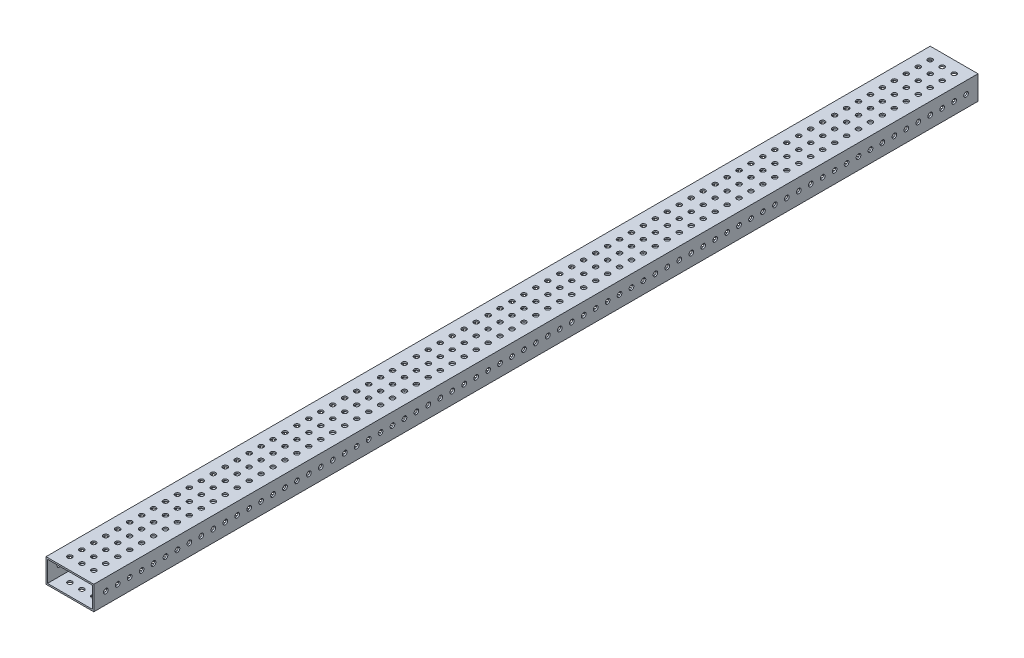
from build123d import *

# Parameters (mm, degrees)
SKETCH1_W           = 50.8
SKETCH1_H           = 25.4
SKETCH1_W_2         = 47.625
SKETCH1_H_2         = 22.225
BOSS_EXTRUDE1_DEPTH = 939.8
SKETCH2_R           = 2.4892
CUT_EXTRUDE1_DEPTH  = 51.8
SKETCH3_R           = 2.4892
CUT_EXTRUDE2_DEPTH  = 26.4


with BuildPart() as part:
    # Sketch1 → Boss-Extrude1 (new body)
    with BuildSketch(Plane.XY):
        with Locations((25.4, 12.7)):
            Rectangle(SKETCH1_W, SKETCH1_H)
        with Locations((25.4, 12.7)):
            Rectangle(SKETCH1_W_2, SKETCH1_H_2, mode=Mode.SUBTRACT)
    extrude(amount=BOSS_EXTRUDE1_DEPTH)

    # Sketch2 → Cut-Extrude1 (cut, through all)
    with BuildSketch(Plane(origin=(50.8, 0, 0), x_dir=(0, 0, -1), z_dir=(1, 0, 0))):
        with Locations((-927.1, 12.7)):
            Circle(SKETCH2_R)
        with Locations((-914.4, 12.7)):
            Circle(SKETCH2_R)
        with Locations((-901.7, 12.7)):
            Circle(SKETCH2_R)
        with Locations((-889, 12.7)):
            Circle(SKETCH2_R)
        with Locations((-876.3, 12.7)):
            Circle(SKETCH2_R)
        with Locations((-863.6, 12.7)):
            Circle(SKETCH2_R)
        with Locations((-850.9, 12.7)):
            Circle(SKETCH2_R)
        with Locations((-838.2, 12.7)):
            Circle(SKETCH2_R)
        with Locations((-825.5, 12.7)):
            Circle(SKETCH2_R)
        with Locations((-812.8, 12.7)):
            Circle(SKETCH2_R)
        with Locations((-800.1, 12.7)):
            Circle(SKETCH2_R)
        with Locations((-787.4, 12.7)):
            Circle(SKETCH2_R)
        with Locations((-774.7, 12.7)):
            Circle(SKETCH2_R)
        with Locations((-762, 12.7)):
            Circle(SKETCH2_R)
        with Locations((-749.3, 12.7)):
            Circle(SKETCH2_R)
        with Locations((-736.6, 12.7)):
            Circle(SKETCH2_R)
        with Locations((-723.9, 12.7)):
            Circle(SKETCH2_R)
        with Locations((-711.2, 12.7)):
            Circle(SKETCH2_R)
        with Locations((-698.5, 12.7)):
            Circle(SKETCH2_R)
        with Locations((-685.8, 12.7)):
            Circle(SKETCH2_R)
        with Locations((-673.1, 12.7)):
            Circle(SKETCH2_R)
        with Locations((-660.4, 12.7)):
            Circle(SKETCH2_R)
        with Locations((-647.7, 12.7)):
            Circle(SKETCH2_R)
        with Locations((-635, 12.7)):
            Circle(SKETCH2_R)
        with Locations((-622.3, 12.7)):
            Circle(SKETCH2_R)
        with Locations((-609.6, 12.7)):
            Circle(SKETCH2_R)
        with Locations((-596.9, 12.7)):
            Circle(SKETCH2_R)
        with Locations((-584.2, 12.7)):
            Circle(SKETCH2_R)
        with Locations((-571.5, 12.7)):
            Circle(SKETCH2_R)
        with Locations((-558.8, 12.7)):
            Circle(SKETCH2_R)
        with Locations((-546.1, 12.7)):
            Circle(SKETCH2_R)
        with Locations((-533.4, 12.7)):
            Circle(SKETCH2_R)
        with Locations((-520.7, 12.7)):
            Circle(SKETCH2_R)
        with Locations((-508, 12.7)):
            Circle(SKETCH2_R)
        with Locations((-495.3, 12.7)):
            Circle(SKETCH2_R)
        with Locations((-482.6, 12.7)):
            Circle(SKETCH2_R)
        with Locations((-469.9, 12.7)):
            Circle(SKETCH2_R)
        with Locations((-457.2, 12.7)):
            Circle(SKETCH2_R)
        with Locations((-444.5, 12.7)):
            Circle(SKETCH2_R)
        with Locations((-431.8, 12.7)):
            Circle(SKETCH2_R)
        with Locations((-419.1, 12.7)):
            Circle(SKETCH2_R)
        with Locations((-406.4, 12.7)):
            Circle(SKETCH2_R)
        with Locations((-393.7, 12.7)):
            Circle(SKETCH2_R)
        with Locations((-381, 12.7)):
            Circle(SKETCH2_R)
        with Locations((-368.3, 12.7)):
            Circle(SKETCH2_R)
        with Locations((-355.6, 12.7)):
            Circle(SKETCH2_R)
        with Locations((-342.9, 12.7)):
            Circle(SKETCH2_R)
        with Locations((-330.2, 12.7)):
            Circle(SKETCH2_R)
        with Locations((-317.5, 12.7)):
            Circle(SKETCH2_R)
        with Locations((-304.8, 12.7)):
            Circle(SKETCH2_R)
        with Locations((-292.1, 12.7)):
            Circle(SKETCH2_R)
        with Locations((-279.4, 12.7)):
            Circle(SKETCH2_R)
        with Locations((-266.7, 12.7)):
            Circle(SKETCH2_R)
        with Locations((-254, 12.7)):
            Circle(SKETCH2_R)
        with Locations((-241.3, 12.7)):
            Circle(SKETCH2_R)
        with Locations((-228.6, 12.7)):
            Circle(SKETCH2_R)
        with Locations((-215.9, 12.7)):
            Circle(SKETCH2_R)
        with Locations((-203.2, 12.7)):
            Circle(SKETCH2_R)
        with Locations((-190.5, 12.7)):
            Circle(SKETCH2_R)
        with Locations((-177.8, 12.7)):
            Circle(SKETCH2_R)
        with Locations((-165.1, 12.7)):
            Circle(SKETCH2_R)
        with Locations((-152.4, 12.7)):
            Circle(SKETCH2_R)
        with Locations((-139.7, 12.7)):
            Circle(SKETCH2_R)
        with Locations((-127, 12.7)):
            Circle(SKETCH2_R)
        with Locations((-114.3, 12.7)):
            Circle(SKETCH2_R)
        with Locations((-101.6, 12.7)):
            Circle(SKETCH2_R)
        with Locations((-88.9, 12.7)):
            Circle(SKETCH2_R)
        with Locations((-76.2, 12.7)):
            Circle(SKETCH2_R)
        with Locations((-63.5, 12.7)):
            Circle(SKETCH2_R)
        with Locations((-50.8, 12.7)):
            Circle(SKETCH2_R)
        with Locations((-38.1, 12.7)):
            Circle(SKETCH2_R)
        with Locations((-25.4, 12.7)):
            Circle(SKETCH2_R)
        with Locations((-12.7, 12.7)):
            Circle(SKETCH2_R)
    extrude(amount=-CUT_EXTRUDE1_DEPTH, mode=Mode.SUBTRACT)

    # Sketch3 → Cut-Extrude2 (cut, through all)
    with BuildSketch(Plane(origin=(0, 25.4, 0), x_dir=(1, 0, 0), z_dir=(0, 1, 0))):
        with Locations((12.7, -12.7)):
            Circle(SKETCH3_R)
        with Locations((25.4, -12.7)):
            Circle(SKETCH3_R)
        with Locations((38.1, -12.7)):
            Circle(SKETCH3_R)
        with Locations((25.4, -25.4)):
            Circle(SKETCH3_R)
        with Locations((38.1, -25.4)):
            Circle(SKETCH3_R)
        with Locations((25.4, -38.1)):
            Circle(SKETCH3_R)
        with Locations((38.1, -38.1)):
            Circle(SKETCH3_R)
        with Locations((25.4, -50.8)):
            Circle(SKETCH3_R)
        with Locations((38.1, -50.8)):
            Circle(SKETCH3_R)
        with Locations((25.4, -63.5)):
            Circle(SKETCH3_R)
        with Locations((38.1, -63.5)):
            Circle(SKETCH3_R)
        with Locations((25.4, -76.2)):
            Circle(SKETCH3_R)
        with Locations((38.1, -76.2)):
            Circle(SKETCH3_R)
        with Locations((25.4, -88.9)):
            Circle(SKETCH3_R)
        with Locations((38.1, -88.9)):
            Circle(SKETCH3_R)
        with Locations((25.4, -101.6)):
            Circle(SKETCH3_R)
        with Locations((38.1, -101.6)):
            Circle(SKETCH3_R)
        with Locations((25.4, -114.3)):
            Circle(SKETCH3_R)
        with Locations((38.1, -114.3)):
            Circle(SKETCH3_R)
        with Locations((25.4, -127)):
            Circle(SKETCH3_R)
        with Locations((38.1, -127)):
            Circle(SKETCH3_R)
        with Locations((25.4, -139.7)):
            Circle(SKETCH3_R)
        with Locations((38.1, -139.7)):
            Circle(SKETCH3_R)
        with Locations((25.4, -152.4)):
            Circle(SKETCH3_R)
        with Locations((38.1, -152.4)):
            Circle(SKETCH3_R)
        with Locations((25.4, -165.1)):
            Circle(SKETCH3_R)
        with Locations((38.1, -165.1)):
            Circle(SKETCH3_R)
        with Locations((25.4, -177.8)):
            Circle(SKETCH3_R)
        with Locations((38.1, -177.8)):
            Circle(SKETCH3_R)
        with Locations((25.4, -190.5)):
            Circle(SKETCH3_R)
        with Locations((38.1, -190.5)):
            Circle(SKETCH3_R)
        with Locations((25.4, -203.2)):
            Circle(SKETCH3_R)
        with Locations((38.1, -203.2)):
            Circle(SKETCH3_R)
        with Locations((25.4, -215.9)):
            Circle(SKETCH3_R)
        with Locations((38.1, -215.9)):
            Circle(SKETCH3_R)
        with Locations((25.4, -228.6)):
            Circle(SKETCH3_R)
        with Locations((38.1, -228.6)):
            Circle(SKETCH3_R)
        with Locations((25.4, -241.3)):
            Circle(SKETCH3_R)
        with Locations((38.1, -241.3)):
            Circle(SKETCH3_R)
        with Locations((25.4, -254)):
            Circle(SKETCH3_R)
        with Locations((38.1, -254)):
            Circle(SKETCH3_R)
        with Locations((25.4, -266.7)):
            Circle(SKETCH3_R)
        with Locations((38.1, -266.7)):
            Circle(SKETCH3_R)
        with Locations((25.4, -279.4)):
            Circle(SKETCH3_R)
        with Locations((38.1, -279.4)):
            Circle(SKETCH3_R)
        with Locations((25.4, -292.1)):
            Circle(SKETCH3_R)
        with Locations((38.1, -292.1)):
            Circle(SKETCH3_R)
        with Locations((25.4, -304.8)):
            Circle(SKETCH3_R)
        with Locations((38.1, -304.8)):
            Circle(SKETCH3_R)
        with Locations((25.4, -317.5)):
            Circle(SKETCH3_R)
        with Locations((38.1, -317.5)):
            Circle(SKETCH3_R)
        with Locations((25.4, -330.2)):
            Circle(SKETCH3_R)
        with Locations((38.1, -330.2)):
            Circle(SKETCH3_R)
        with Locations((25.4, -342.9)):
            Circle(SKETCH3_R)
        with Locations((38.1, -342.9)):
            Circle(SKETCH3_R)
        with Locations((25.4, -355.6)):
            Circle(SKETCH3_R)
        with Locations((38.1, -355.6)):
            Circle(SKETCH3_R)
        with Locations((25.4, -368.3)):
            Circle(SKETCH3_R)
        with Locations((38.1, -368.3)):
            Circle(SKETCH3_R)
        with Locations((25.4, -381)):
            Circle(SKETCH3_R)
        with Locations((38.1, -381)):
            Circle(SKETCH3_R)
        with Locations((25.4, -393.7)):
            Circle(SKETCH3_R)
        with Locations((38.1, -393.7)):
            Circle(SKETCH3_R)
        with Locations((25.4, -406.4)):
            Circle(SKETCH3_R)
        with Locations((38.1, -406.4)):
            Circle(SKETCH3_R)
        with Locations((25.4, -419.1)):
            Circle(SKETCH3_R)
        with Locations((38.1, -419.1)):
            Circle(SKETCH3_R)
        with Locations((25.4, -431.8)):
            Circle(SKETCH3_R)
        with Locations((38.1, -431.8)):
            Circle(SKETCH3_R)
        with Locations((25.4, -444.5)):
            Circle(SKETCH3_R)
        with Locations((38.1, -444.5)):
            Circle(SKETCH3_R)
        with Locations((25.4, -457.2)):
            Circle(SKETCH3_R)
        with Locations((38.1, -457.2)):
            Circle(SKETCH3_R)
        with Locations((25.4, -469.9)):
            Circle(SKETCH3_R)
        with Locations((38.1, -469.9)):
            Circle(SKETCH3_R)
        with Locations((25.4, -482.6)):
            Circle(SKETCH3_R)
        with Locations((38.1, -482.6)):
            Circle(SKETCH3_R)
        with Locations((25.4, -495.3)):
            Circle(SKETCH3_R)
        with Locations((38.1, -495.3)):
            Circle(SKETCH3_R)
        with Locations((25.4, -508)):
            Circle(SKETCH3_R)
        with Locations((38.1, -508)):
            Circle(SKETCH3_R)
        with Locations((25.4, -520.7)):
            Circle(SKETCH3_R)
        with Locations((38.1, -520.7)):
            Circle(SKETCH3_R)
        with Locations((25.4, -533.4)):
            Circle(SKETCH3_R)
        with Locations((38.1, -533.4)):
            Circle(SKETCH3_R)
        with Locations((25.4, -546.1)):
            Circle(SKETCH3_R)
        with Locations((38.1, -546.1)):
            Circle(SKETCH3_R)
        with Locations((25.4, -558.8)):
            Circle(SKETCH3_R)
        with Locations((38.1, -558.8)):
            Circle(SKETCH3_R)
        with Locations((25.4, -571.5)):
            Circle(SKETCH3_R)
        with Locations((38.1, -571.5)):
            Circle(SKETCH3_R)
        with Locations((25.4, -584.2)):
            Circle(SKETCH3_R)
        with Locations((38.1, -584.2)):
            Circle(SKETCH3_R)
        with Locations((25.4, -596.9)):
            Circle(SKETCH3_R)
        with Locations((38.1, -596.9)):
            Circle(SKETCH3_R)
        with Locations((25.4, -609.6)):
            Circle(SKETCH3_R)
        with Locations((38.1, -609.6)):
            Circle(SKETCH3_R)
        with Locations((25.4, -622.3)):
            Circle(SKETCH3_R)
        with Locations((38.1, -622.3)):
            Circle(SKETCH3_R)
        with Locations((25.4, -635)):
            Circle(SKETCH3_R)
        with Locations((38.1, -635)):
            Circle(SKETCH3_R)
        with Locations((25.4, -647.7)):
            Circle(SKETCH3_R)
        with Locations((38.1, -647.7)):
            Circle(SKETCH3_R)
        with Locations((25.4, -660.4)):
            Circle(SKETCH3_R)
        with Locations((38.1, -660.4)):
            Circle(SKETCH3_R)
        with Locations((25.4, -673.1)):
            Circle(SKETCH3_R)
        with Locations((38.1, -673.1)):
            Circle(SKETCH3_R)
        with Locations((25.4, -685.8)):
            Circle(SKETCH3_R)
        with Locations((38.1, -685.8)):
            Circle(SKETCH3_R)
        with Locations((25.4, -698.5)):
            Circle(SKETCH3_R)
        with Locations((38.1, -698.5)):
            Circle(SKETCH3_R)
        with Locations((25.4, -711.2)):
            Circle(SKETCH3_R)
        with Locations((38.1, -711.2)):
            Circle(SKETCH3_R)
        with Locations((25.4, -723.9)):
            Circle(SKETCH3_R)
        with Locations((38.1, -723.9)):
            Circle(SKETCH3_R)
        with Locations((25.4, -736.6)):
            Circle(SKETCH3_R)
        with Locations((38.1, -736.6)):
            Circle(SKETCH3_R)
        with Locations((25.4, -749.3)):
            Circle(SKETCH3_R)
        with Locations((38.1, -749.3)):
            Circle(SKETCH3_R)
        with Locations((25.4, -762)):
            Circle(SKETCH3_R)
        with Locations((38.1, -762)):
            Circle(SKETCH3_R)
        with Locations((25.4, -774.7)):
            Circle(SKETCH3_R)
        with Locations((38.1, -774.7)):
            Circle(SKETCH3_R)
        with Locations((25.4, -787.4)):
            Circle(SKETCH3_R)
        with Locations((38.1, -787.4)):
            Circle(SKETCH3_R)
        with Locations((25.4, -800.1)):
            Circle(SKETCH3_R)
        with Locations((38.1, -800.1)):
            Circle(SKETCH3_R)
        with Locations((25.4, -812.8)):
            Circle(SKETCH3_R)
        with Locations((38.1, -812.8)):
            Circle(SKETCH3_R)
        with Locations((25.4, -825.5)):
            Circle(SKETCH3_R)
        with Locations((38.1, -825.5)):
            Circle(SKETCH3_R)
        with Locations((25.4, -838.2)):
            Circle(SKETCH3_R)
        with Locations((38.1, -838.2)):
            Circle(SKETCH3_R)
        with Locations((25.4, -850.9)):
            Circle(SKETCH3_R)
        with Locations((38.1, -850.9)):
            Circle(SKETCH3_R)
        with Locations((25.4, -863.6)):
            Circle(SKETCH3_R)
        with Locations((38.1, -863.6)):
            Circle(SKETCH3_R)
        with Locations((25.4, -876.3)):
            Circle(SKETCH3_R)
        with Locations((38.1, -876.3)):
            Circle(SKETCH3_R)
        with Locations((25.4, -889)):
            Circle(SKETCH3_R)
        with Locations((38.1, -889)):
            Circle(SKETCH3_R)
        with Locations((25.4, -901.7)):
            Circle(SKETCH3_R)
        with Locations((38.1, -901.7)):
            Circle(SKETCH3_R)
        with Locations((25.4, -914.4)):
            Circle(SKETCH3_R)
        with Locations((38.1, -914.4)):
            Circle(SKETCH3_R)
        with Locations((25.4, -927.1)):
            Circle(SKETCH3_R)
        with Locations((38.1, -927.1)):
            Circle(SKETCH3_R)
        with Locations((12.7, -25.4)):
            Circle(SKETCH3_R)
        with Locations((12.7, -38.1)):
            Circle(SKETCH3_R)
        with Locations((12.7, -50.8)):
            Circle(SKETCH3_R)
        with Locations((12.7, -63.5)):
            Circle(SKETCH3_R)
        with Locations((12.7, -76.2)):
            Circle(SKETCH3_R)
        with Locations((12.7, -88.9)):
            Circle(SKETCH3_R)
        with Locations((12.7, -101.6)):
            Circle(SKETCH3_R)
        with Locations((12.7, -114.3)):
            Circle(SKETCH3_R)
        with Locations((12.7, -127)):
            Circle(SKETCH3_R)
        with Locations((12.7, -139.7)):
            Circle(SKETCH3_R)
        with Locations((12.7, -152.4)):
            Circle(SKETCH3_R)
        with Locations((12.7, -165.1)):
            Circle(SKETCH3_R)
        with Locations((12.7, -177.8)):
            Circle(SKETCH3_R)
        with Locations((12.7, -190.5)):
            Circle(SKETCH3_R)
        with Locations((12.7, -203.2)):
            Circle(SKETCH3_R)
        with Locations((12.7, -215.9)):
            Circle(SKETCH3_R)
        with Locations((12.7, -228.6)):
            Circle(SKETCH3_R)
        with Locations((12.7, -241.3)):
            Circle(SKETCH3_R)
        with Locations((12.7, -254)):
            Circle(SKETCH3_R)
        with Locations((12.7, -266.7)):
            Circle(SKETCH3_R)
        with Locations((12.7, -279.4)):
            Circle(SKETCH3_R)
        with Locations((12.7, -292.1)):
            Circle(SKETCH3_R)
        with Locations((12.7, -304.8)):
            Circle(SKETCH3_R)
        with Locations((12.7, -317.5)):
            Circle(SKETCH3_R)
        with Locations((12.7, -330.2)):
            Circle(SKETCH3_R)
        with Locations((12.7, -342.9)):
            Circle(SKETCH3_R)
        with Locations((12.7, -355.6)):
            Circle(SKETCH3_R)
        with Locations((12.7, -368.3)):
            Circle(SKETCH3_R)
        with Locations((12.7, -381)):
            Circle(SKETCH3_R)
        with Locations((12.7, -393.7)):
            Circle(SKETCH3_R)
        with Locations((12.7, -406.4)):
            Circle(SKETCH3_R)
        with Locations((12.7, -419.1)):
            Circle(SKETCH3_R)
        with Locations((12.7, -431.8)):
            Circle(SKETCH3_R)
        with Locations((12.7, -444.5)):
            Circle(SKETCH3_R)
        with Locations((12.7, -457.2)):
            Circle(SKETCH3_R)
        with Locations((12.7, -469.9)):
            Circle(SKETCH3_R)
        with Locations((12.7, -482.6)):
            Circle(SKETCH3_R)
        with Locations((12.7, -495.3)):
            Circle(SKETCH3_R)
        with Locations((12.7, -508)):
            Circle(SKETCH3_R)
        with Locations((12.7, -520.7)):
            Circle(SKETCH3_R)
        with Locations((12.7, -533.4)):
            Circle(SKETCH3_R)
        with Locations((12.7, -546.1)):
            Circle(SKETCH3_R)
        with Locations((12.7, -558.8)):
            Circle(SKETCH3_R)
        with Locations((12.7, -571.5)):
            Circle(SKETCH3_R)
        with Locations((12.7, -584.2)):
            Circle(SKETCH3_R)
        with Locations((12.7, -596.9)):
            Circle(SKETCH3_R)
        with Locations((12.7, -609.6)):
            Circle(SKETCH3_R)
        with Locations((12.7, -622.3)):
            Circle(SKETCH3_R)
        with Locations((12.7, -635)):
            Circle(SKETCH3_R)
        with Locations((12.7, -647.7)):
            Circle(SKETCH3_R)
        with Locations((12.7, -660.4)):
            Circle(SKETCH3_R)
        with Locations((12.7, -673.1)):
            Circle(SKETCH3_R)
        with Locations((12.7, -685.8)):
            Circle(SKETCH3_R)
        with Locations((12.7, -698.5)):
            Circle(SKETCH3_R)
        with Locations((12.7, -711.2)):
            Circle(SKETCH3_R)
        with Locations((12.7, -723.9)):
            Circle(SKETCH3_R)
        with Locations((12.7, -736.6)):
            Circle(SKETCH3_R)
        with Locations((12.7, -749.3)):
            Circle(SKETCH3_R)
        with Locations((12.7, -762)):
            Circle(SKETCH3_R)
        with Locations((12.7, -774.7)):
            Circle(SKETCH3_R)
        with Locations((12.7, -787.4)):
            Circle(SKETCH3_R)
        with Locations((12.7, -800.1)):
            Circle(SKETCH3_R)
        with Locations((12.7, -812.8)):
            Circle(SKETCH3_R)
        with Locations((12.7, -825.5)):
            Circle(SKETCH3_R)
        with Locations((12.7, -838.2)):
            Circle(SKETCH3_R)
        with Locations((12.7, -850.9)):
            Circle(SKETCH3_R)
        with Locations((12.7, -863.6)):
            Circle(SKETCH3_R)
        with Locations((12.7, -876.3)):
            Circle(SKETCH3_R)
        with Locations((12.7, -889)):
            Circle(SKETCH3_R)
        with Locations((12.7, -901.7)):
            Circle(SKETCH3_R)
        with Locations((12.7, -914.4)):
            Circle(SKETCH3_R)
        with Locations((12.7, -927.1)):
            Circle(SKETCH3_R)
    extrude(amount=-CUT_EXTRUDE2_DEPTH, mode=Mode.SUBTRACT)


solid = part.part
